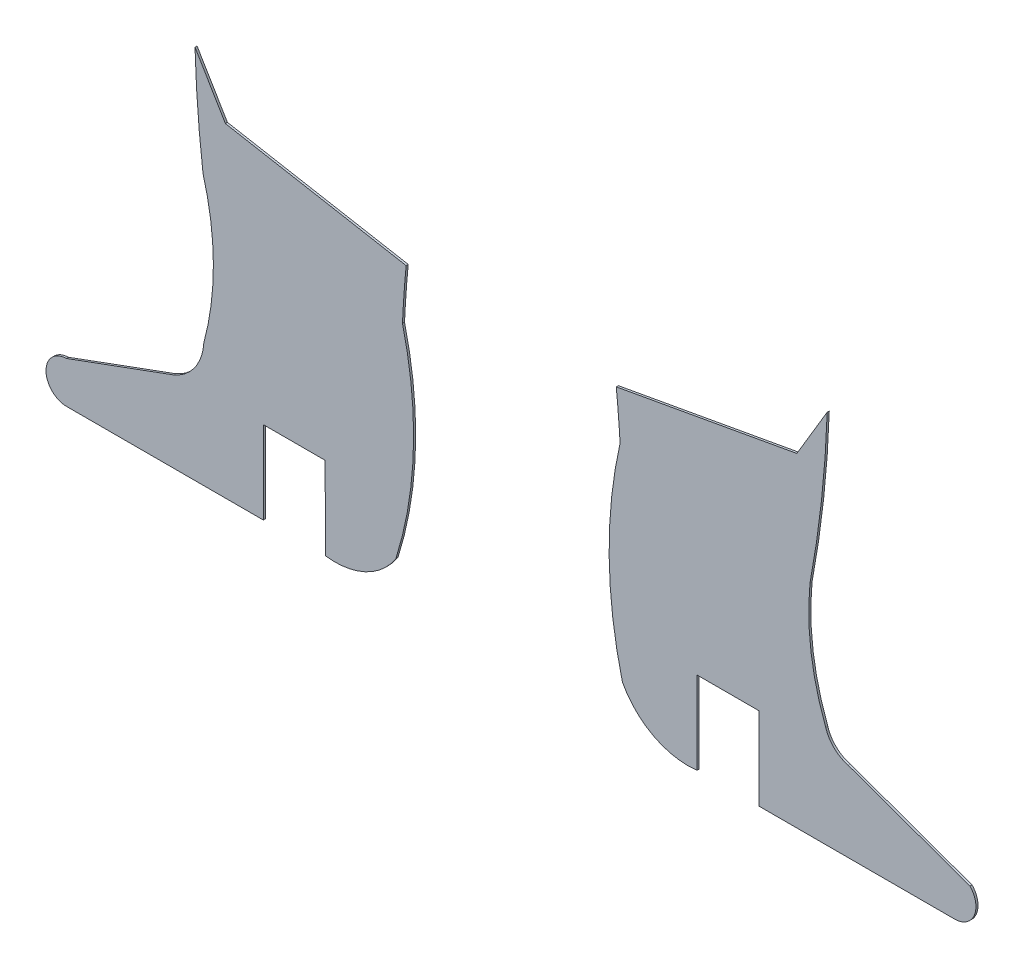
from build123d import *

# Parameters (mm, degrees)
SALIENTE_EXTRUIR1_DEPTH   = 0.1
SALIENTE_EXTRUIR1_2_DEPTH = 0.1


with BuildPart() as part:
    # Model → Saliente-Extruir1 (new body)
    with BuildSketch(Plane.XY):
        with BuildLine():
            Line((26.501269255, -36.068605041), (26.506051465, -40.067662259))
            ThreePointArc((26.506051465, -40.067662259), (28.444344017, -39.771690142), (29.920969094, -38.481668478))
            ThreePointArc((29.920969094, -38.481668478), (30.772348929, -33.491466373), (30.240780395, -28.457144218))
            ThreePointArc((30.240780395, -28.457144218), (30.31487768, -27.198260074), (30.418644104, -25.941473607))
            Line((30.418644104, -25.941473607), (21.66634164, -24.362151891))
            Line((21.66634164, -24.362151891), (20.196850226, -21.897303534))
            ThreePointArc((20.196850226, -21.897303534), (20.330431924, -24.452991033), (20.584617406, -26.999512662))
            ThreePointArc((20.584617406, -26.999512662), (21.086332443, -30.541981177), (20.621577326, -34.089487885))
            ThreePointArc((20.621577326, -34.089487885), (20.188232636, -35.329342735), (19.166265945, -36.154334707))
            Line((19.166265945, -36.154334707), (13.964095848, -38.063123051))
            ThreePointArc((13.964095848, -38.063123051), (12.982047294, -39.088384952), (14.007309194, -40.070433507))
            Line((14.007309194, -40.070433507), (23.506051635, -40.069043418))
            Line((23.506051635, -40.069043418), (23.505466257, -36.06904346))
            Line((23.505466257, -36.06904346), (26.501269255, -36.068605041))
        make_face()
    extrude(amount=SALIENTE_EXTRUIR1_DEPTH)


with BuildPart() as body_2:
    # Model → Saliente-Extruir1 2 (new body)
    with BuildSketch(Plane.XY):
        with BuildLine():
            Line((57.721521483, -38.312071296), (51.822198996, -36.191325411))
            ThreePointArc((51.822198996, -36.191325411), (51.142357203, -35.813382317), (50.735279518, -35.15057495))
            ThreePointArc((50.735279518, -35.15057495), (50.024494027, -32.363382375), (49.971915497, -29.48746618))
            ThreePointArc((49.971915497, -29.48746618), (50.534229917, -25.707596933), (50.80661247, -21.895849724))
            Line((50.80661247, -21.895849724), (49.337355198, -24.360837656))
            Line((49.337355198, -24.360837656), (40.594249402, -25.940135422))
            ThreePointArc((40.594249402, -25.940135422), (40.697813422, -27.073621681), (40.779232989, -28.208913477))
            ThreePointArc((40.779232989, -28.208913477), (40.248038009, -33.195193817), (40.890317085, -38.168385683))
            ThreePointArc((40.890317085, -38.168385683), (42.400635208, -39.679109073), (44.501269255, -40.067287633))
            Line((44.501269255, -40.067287633), (44.501269255, -36.067287633))
            Line((44.501269255, -36.067287633), (47.501269255, -36.067287633))
            Line((47.501269255, -36.067287633), (47.501269255, -40.067287633))
            Line((47.501269255, -40.067287633), (57.03827443, -40.066886334))
            ThreePointArc((57.03827443, -40.066886334), (57.938175953, -39.406847476), (57.721521483, -38.312071296))
        make_face()
    extrude(amount=SALIENTE_EXTRUIR1_2_DEPTH)


solid = Compound([part.part, body_2.part])
